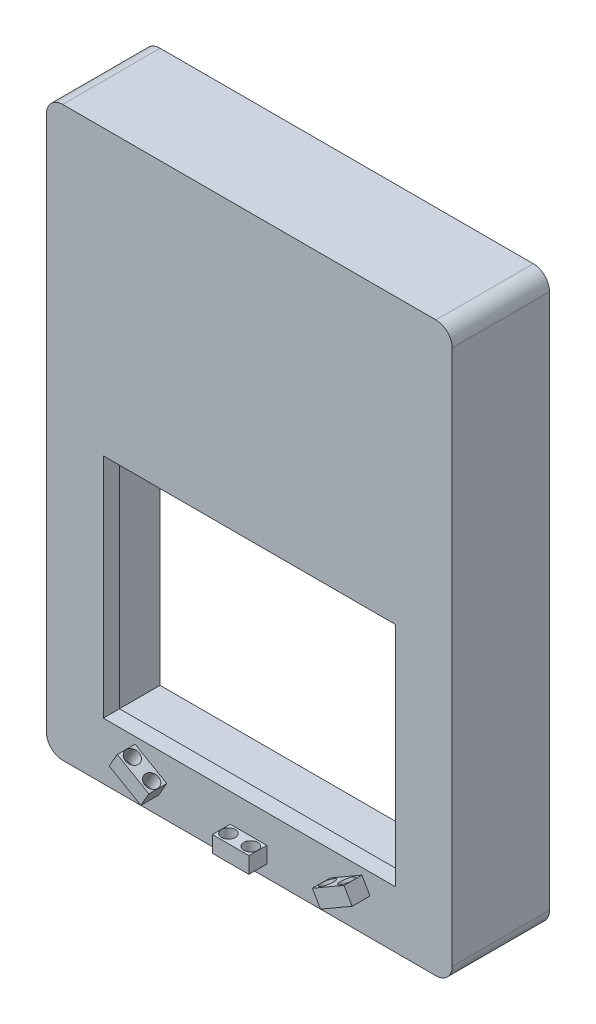
from build123d import *

# Parameters (mm, degrees)
SCHIZZO1_W                     = 500
SCHIZZO1_H                     = 700
ESTRUSIONE_ESTRUSIONE4_DEPTH   = 20
SCHIZZO1_4_W                   = 500
SCHIZZO1_4_H                   = 700
SCHIZZO1_4_W_2                 = 460
SCHIZZO1_4_H_2                 = 660
ESTRUSIONE_ESTRUSIONE5_DEPTH   = 100
ESTRUSIONE_ESTRUSIONE6_START   = 20
ESTRUSIONE_ESTRUSIONE6_DEPTH   = 22
SCHIZZO2_W                     = 45
SCHIZZO2_H                     = 20
ESTRUSIONE_ESTRUSIONE6_2_DEPTH = 22
ESTRUSIONE_ESTRUSIONE7_START   = 20
ESTRUSIONE_ESTRUSIONE7_DEPTH   = 22
SCHIZZO6_R                     = 8.5
TAGLIO_ESTRUSIONE1_DEPTH       = 22
SCHIZZO7_R                     = 8.5
TAGLIO_ESTRUSIONE2_DEPTH       = 22
SCHIZZO8_R                     = 8.5
TAGLIO_ESTRUSIONE3_DEPTH       = 22
SCHIZZO10_W                    = 360
SCHIZZO10_H                    = 280
TAGLIO_ESTRUSIONE4_DEPTH       = 22
RACCORDO1_R                    = 20
RACCORDO2_R                    = 20
RACCORDO3_R                    = 20
RACCORDO4_R                    = 20


with BuildPart() as part:
    # Schizzo1 → Estrusione-Estrusione4 (new body)
    with BuildSketch(Plane.XY):
        with Locations((250, -350)):
            Rectangle(SCHIZZO1_W, SCHIZZO1_H)
    extrude(amount=ESTRUSIONE_ESTRUSIONE4_DEPTH)

    # Schizzo1_4 → Estrusione-Estrusione5 (add)
    with BuildSketch(Plane.XY):
        with Locations((250, -350)):
            Rectangle(SCHIZZO1_4_W, SCHIZZO1_4_H)
        with Locations((250, -350)):
            Rectangle(SCHIZZO1_4_W_2, SCHIZZO1_4_H_2, mode=Mode.SUBTRACT)
    extrude(amount=-ESTRUSIONE_ESTRUSIONE5_DEPTH)

    # Schizzo2_3 → Estrusione-Estrusione7 (add)
    with BuildSketch(Plane.XY.offset(ESTRUSIONE_ESTRUSIONE7_START)):
        Polygon((359.75, -677.989883085), (398.72114317, -655.489883085), (388.72114317, -638.169375009), (349.75, -660.669375009), align=None)
    extrude(amount=ESTRUSIONE_ESTRUSIONE7_DEPTH)

    # Schizzo8 → Taglio-Estrusione3 (cut)
    with BuildSketch(Plane(origin=(383.51573113, -664.26873182, 0), x_dir=(0.866025404, 0.5, 0), z_dir=(0.5, -0.866025404, 0))):
        with Locations((-18.692302531, 31)):
            Circle(SCHIZZO8_R)
        with Locations((8.807697469, 31)):
            Circle(SCHIZZO8_R)
    extrude(amount=-TAGLIO_ESTRUSIONE3_DEPTH, mode=Mode.SUBTRACT)

    # Schizzo10 → Taglio-Estrusione4 (cut)
    with BuildSketch(Plane.XY.offset(20)):
        with Locations((250, -490)):
            Rectangle(SCHIZZO10_W, SCHIZZO10_H)
    extrude(amount=-TAGLIO_ESTRUSIONE4_DEPTH, mode=Mode.SUBTRACT)

    # Raccordo1
    raccordo1_edges = [part.edges().sort_by_distance(p)[0] for p in [
        (0, 0, -40),
    ]]
    fillet(raccordo1_edges, radius=RACCORDO1_R)

    # Raccordo2
    raccordo2_edges = [part.edges().sort_by_distance(p)[0] for p in [
        (500, 0, -40),
    ]]
    fillet(raccordo2_edges, radius=RACCORDO2_R)

    # Raccordo3
    raccordo3_edges = [part.edges().sort_by_distance(p)[0] for p in [
        (500, -700, -40),
    ]]
    fillet(raccordo3_edges, radius=RACCORDO3_R)

    # Raccordo4
    raccordo4_edges = [part.edges().sort_by_distance(p)[0] for p in [
        (0, -700, -40),
    ]]
    fillet(raccordo4_edges, radius=RACCORDO4_R)


with BuildPart() as body_2:
    # Schizzo2 → Estrusione-Estrusione6 (new body)
    with BuildSketch(Plane.XY.offset(ESTRUSIONE_ESTRUSIONE6_START)):
        Polygon((148.250287501, -660.670038978), (138.249137563, -677.989883085), (99.279144353, -655.490547015), (109.279144331, -638.170038978), align=None)
    extrude(amount=ESTRUSIONE_ESTRUSIONE6_DEPTH)

    # Schizzo6 → Taglio-Estrusione1 (cut)
    with BuildSketch(Plane(origin=(-259.01594674, -448.628779724, 0), x_dir=(0.866025404, -0.5, 0), z_dir=(-0.5, -0.866025404, 0))):
        with Locations((422.472870653, 31)):
            Circle(SCHIZZO6_R)
        with Locations((449.972870653, 31)):
            Circle(SCHIZZO6_R)
    extrude(amount=-TAGLIO_ESTRUSIONE1_DEPTH, mode=Mode.SUBTRACT)


with BuildPart() as body_3:
    # Schizzo2 → Estrusione-Estrusione6 2 (new body)
    with BuildSketch(Plane.XY.offset(ESTRUSIONE_ESTRUSIONE6_START)):
        with Locations((249, -675)):
            Rectangle(SCHIZZO2_W, SCHIZZO2_H)
    extrude(amount=ESTRUSIONE_ESTRUSIONE6_2_DEPTH)

    # Schizzo7 → Taglio-Estrusione2 (cut)
    with BuildSketch(Plane.XZ.offset(685)):
        with Locations((235.25, 31)):
            Circle(SCHIZZO7_R)
        with Locations((262.75, 31)):
            Circle(SCHIZZO7_R)
    extrude(amount=-TAGLIO_ESTRUSIONE2_DEPTH, mode=Mode.SUBTRACT)


solid = Compound([part.part, body_2.part, body_3.part])
